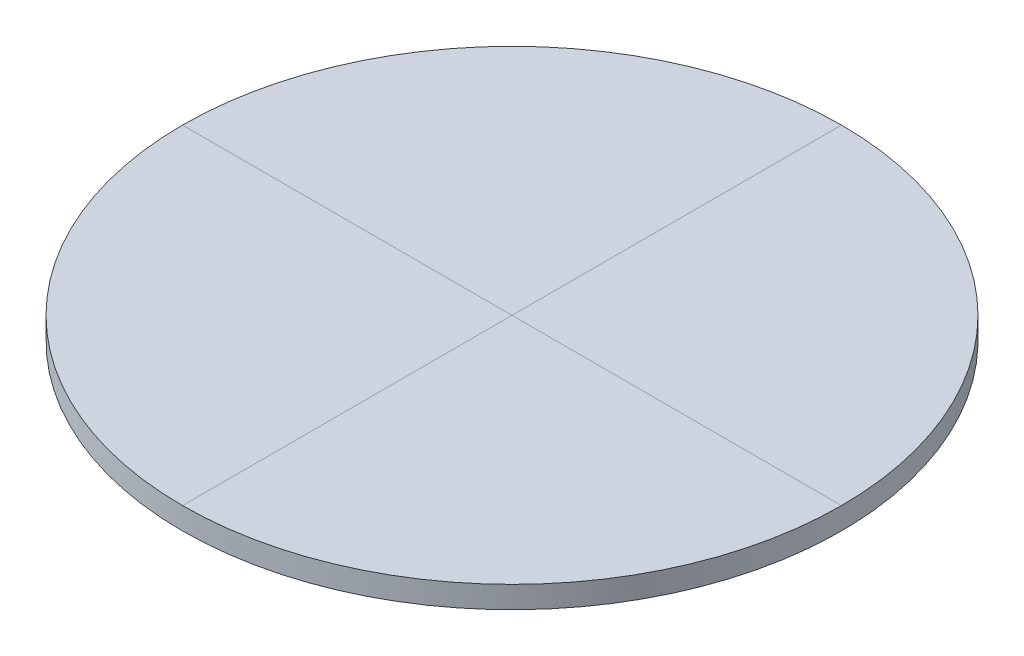
from build123d import *

# Parameters (mm, degrees)
SKETCH1_R           = 15
BOSS_EXTRUDE1_DEPTH = 1


with BuildPart() as part:
    # Sketch1 → Boss-Extrude1 (new body)
    with BuildSketch(Plane(origin=(0, 0, 0), x_dir=(1, 0, 0), z_dir=(0, 1, 0))):
        Circle(SKETCH1_R)
    extrude(amount=BOSS_EXTRUDE1_DEPTH)


solid = part.part
